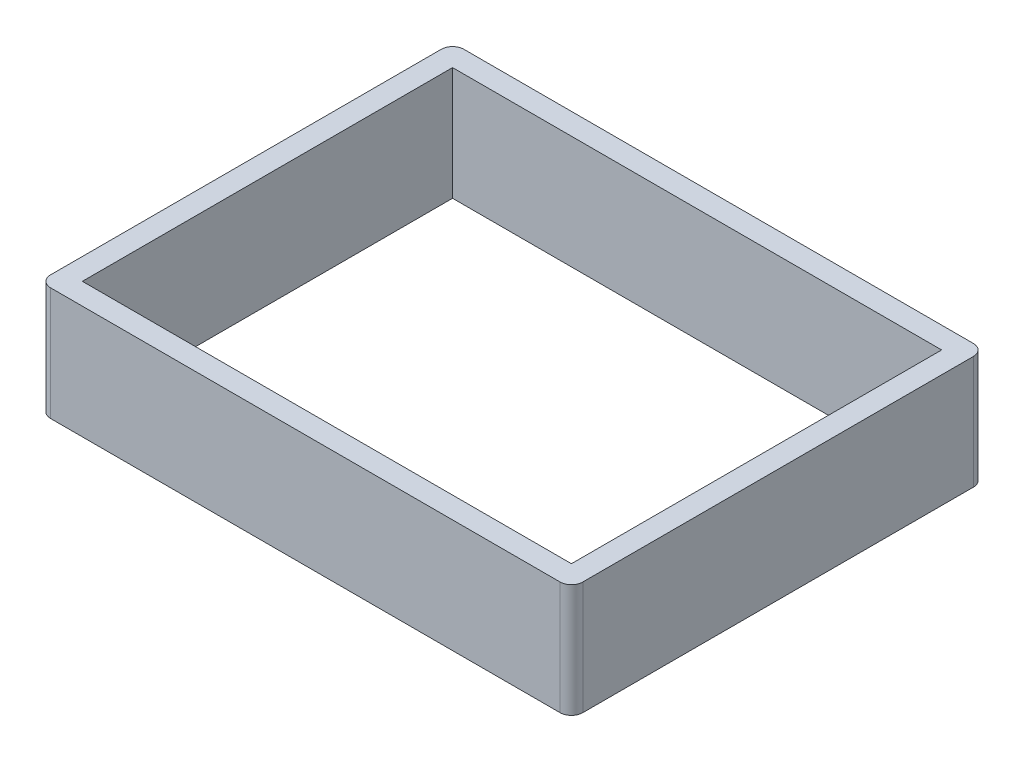
from build123d import *

# Parameters (mm, degrees)
SKETCH2_W           = 119.38
SKETCH2_H           = 92.71
SKETCH2_W_2         = 109.728
SKETCH2_H_2         = 83.058
BOSS_EXTRUDE1_DEPTH = 25.4
FILLET1_R           = 2.54


with BuildPart() as part:
    # Sketch2 → Boss-Extrude1 (new body)
    with BuildSketch(Plane(origin=(0, 0, 0), x_dir=(1, 0, 0), z_dir=(0, 1, 0))):
        with Locations((59.69, 46.355)):
            Rectangle(SKETCH2_W, SKETCH2_H)
        with Locations((59.69, 46.355)):
            Rectangle(SKETCH2_W_2, SKETCH2_H_2, mode=Mode.SUBTRACT)
    extrude(amount=BOSS_EXTRUDE1_DEPTH)

    # Fillet1
    fillet1_edges = [part.edges().sort_by_distance(p)[0] for p in [
        (0, 12.7, -92.71),
        (119.38, 12.7, -92.71),
        (119.38, 12.7, 0),
        (0, 12.7, 0),
    ]]
    fillet(fillet1_edges, radius=FILLET1_R)


solid = part.part
